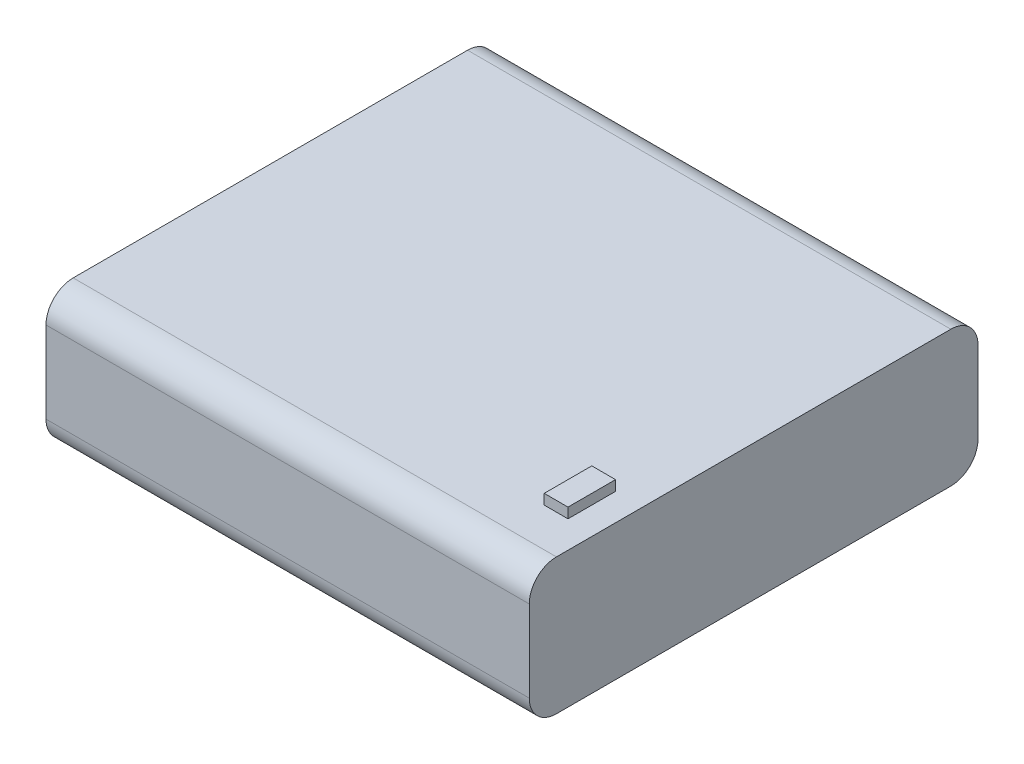
from build123d import *

# Parameters (mm, degrees)
SKETCH1_W           = 71.12
SKETCH1_H           = 66.04
BOSS_EXTRUDE1_DEPTH = 20
FILLET1_R           = 4
SKETCH2_W           = 3.5
SKETCH2_H           = 7
BOSS_EXTRUDE2_DEPTH = 1.5


with BuildPart() as part:
    # Sketch1 → Boss-Extrude1 (new body)
    with BuildSketch(Plane(origin=(0, 0, 0), x_dir=(1, 0, 0), z_dir=(0, 1, 0))):
        Rectangle(SKETCH1_W, SKETCH1_H)
    extrude(amount=BOSS_EXTRUDE1_DEPTH)

    # Fillet1
    fillet1_edges = [part.edges().sort_by_distance(p)[0] for p in [
        (0, 20, 33.02),
        (0, 0, 33.02),
        (0, 0, -33.02),
        (0, 20, -33.02),
    ]]
    fillet(fillet1_edges, radius=FILLET1_R)

    # Sketch2 → Boss-Extrude2 (add)
    with BuildSketch(Plane(origin=(0, 20, 0), x_dir=(1, 0, 0), z_dir=(0, 1, 0))):
        with Locations((29.81, -19.82)):
            Rectangle(SKETCH2_W, SKETCH2_H)
    extrude(amount=BOSS_EXTRUDE2_DEPTH)


solid = part.part
